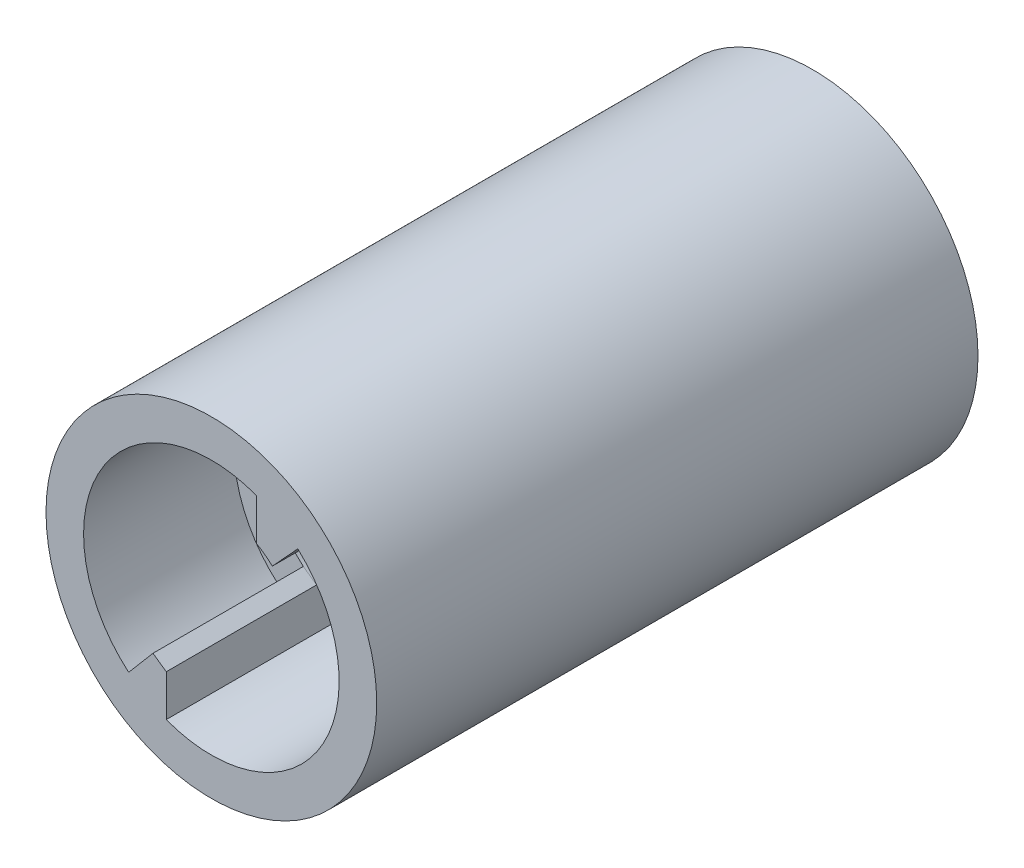
from build123d import *

# Parameters (mm, degrees)
CROQUIS1_R              = 11
CROQUIS1_R_2            = 6
SALIENTE_EXTRUIR1_DEPTH = 25
CROQUIS2_W              = 6
CROQUIS2_H              = 22
CORTAR_EXTRUIR1_DEPTH   = 25
CROQUIS3_R              = 11
CROQUIS3_R_2            = 8.5
SALIENTE_EXTRUIR2_DEPTH = 25
SALIENTE_EXTRUIR3_DEPTH = 10
SALIENTE_EXTRUIR4_DEPTH = 10
CROQUIS9_R              = 11
CROQUIS9_R_2            = 8.5
SALIENTE_EXTRUIR5_DEPTH = 10
CROQUIS13_R             = 11
CROQUIS13_R_2           = 6
SALIENTE_EXTRUIR6_DEPTH = 5
CROQUIS14_W             = 6
CROQUIS14_H             = 22
CORTAR_EXTRUIR2_DEPTH   = 5
CROQUIS15_R             = 11
CROQUIS15_R_2           = 8.5
SALIENTE_EXTRUIR7_DEPTH = 5


with BuildPart() as part:
    # Croquis1 → Saliente-Extruir1 (new body)
    with BuildSketch(Plane.XY):
        Circle(CROQUIS1_R)
        Circle(CROQUIS1_R_2, mode=Mode.SUBTRACT)
    extrude(amount=SALIENTE_EXTRUIR1_DEPTH)

    # Croquis2 → Cortar-Extruir1 (cut)
    with BuildSketch(Plane.XY.offset(25)):
        Rectangle(CROQUIS2_W, CROQUIS2_H)
    extrude(amount=-CORTAR_EXTRUIR1_DEPTH, mode=Mode.SUBTRACT)

    # Croquis3 → Saliente-Extruir2 (add)
    with BuildSketch(Plane.XY):
        Circle(CROQUIS3_R)
        Circle(CROQUIS3_R_2, mode=Mode.SUBTRACT)
    extrude(amount=SALIENTE_EXTRUIR2_DEPTH)

    # Croquis4 → Saliente-Extruir3 (add)
    with BuildSketch(Plane.XY.offset(25)):
        with BuildLine():
            Line((3, 5.196152423), (3, 10.583005244))
            ThreePointArc((3, 10.583005244), (5.366490611, 9.602123647), (7.441930866, 8.100473133))
            Line((7.441930866, 8.100473133), (4.059235018, 4.418439891))
            ThreePointArc((4.059235018, 4.418439891), (3.550972959, 4.83638202), (3, 5.196152423))
        make_face()
    extrude(amount=SALIENTE_EXTRUIR3_DEPTH)

    # Croquis8 → Saliente-Extruir4 (add)
    with BuildSketch(Plane.XY.offset(25)):
        Polygon((-3, -10.583005244), (-3, -5.196152423), (-3.883308042, -4.573829758), (-7.119398076, -8.385354556), align=None)
    extrude(amount=SALIENTE_EXTRUIR4_DEPTH)

    # Croquis9 → Saliente-Extruir5 (add)
    with BuildSketch(Plane.XY.offset(25)):
        Circle(CROQUIS9_R)
        Circle(CROQUIS9_R_2, mode=Mode.SUBTRACT)
    extrude(amount=SALIENTE_EXTRUIR5_DEPTH)

    # Croquis13 → Saliente-Extruir6 (add)
    with BuildSketch(Plane(origin=(0, 0, 0), x_dir=(-1, 0, 0), z_dir=(0, 0, -1))):
        Circle(CROQUIS13_R)
        Circle(CROQUIS13_R_2, mode=Mode.SUBTRACT)
    extrude(amount=SALIENTE_EXTRUIR6_DEPTH)

    # Croquis14 → Cortar-Extruir2 (cut)
    with BuildSketch(Plane(origin=(0, 0, -5), x_dir=(-1, 0, 0), z_dir=(0, 0, -1))):
        Rectangle(CROQUIS14_W, CROQUIS14_H)
    extrude(amount=-CORTAR_EXTRUIR2_DEPTH, mode=Mode.SUBTRACT)

    # Croquis15 → Saliente-Extruir7 (add)
    with BuildSketch(Plane(origin=(0, 0, -5), x_dir=(-1, 0, 0), z_dir=(0, 0, -1))):
        Circle(CROQUIS15_R)
        Circle(CROQUIS15_R_2, mode=Mode.SUBTRACT)
    extrude(amount=-SALIENTE_EXTRUIR7_DEPTH)


solid = part.part
